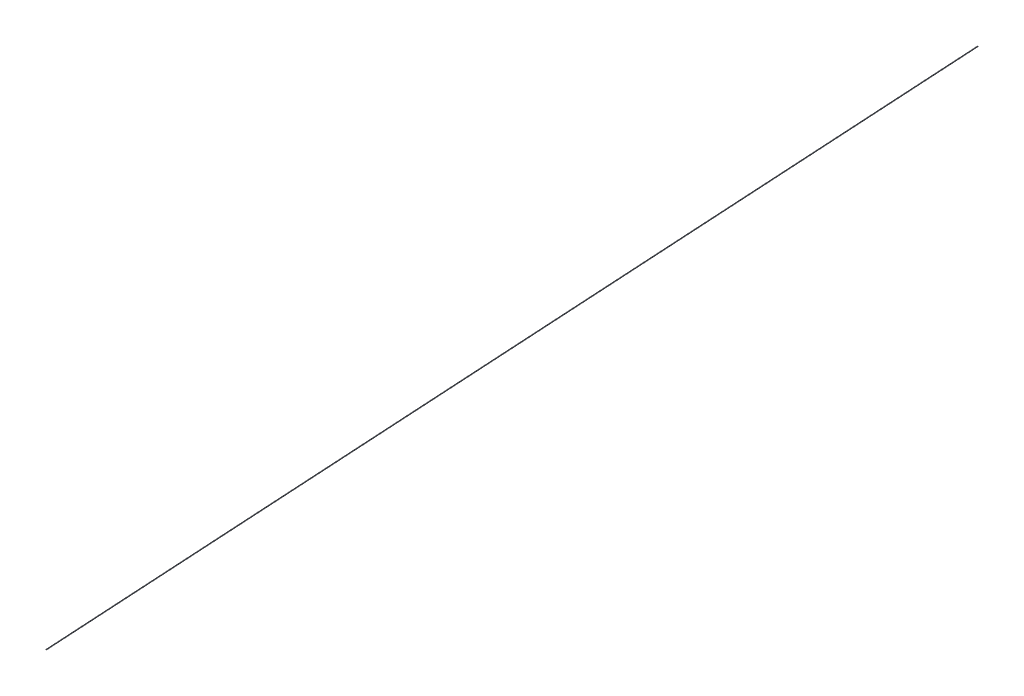
from build123d import *

# Parameters (mm, degrees)
SKETCH2_R = 3.8


with BuildPart() as part:
    # Sweep1: sweep along a path in Sketch1
    with BuildLine(Plane(origin=(0, 0, 0), x_dir=(0, 0, -1), z_dir=(1, 0, 0))) as sweep1_path:
        Line((14101.6, 857.6), (14091.6, 857.6))
        Line((14091.6, 857.6), (10, 0))
        Line((10, 0), (0, 0))
    # Sketch2 → Sweep1 (sweep)
    with BuildSketch(Plane.XY):
        Circle(SKETCH2_R)
    sweep(path=sweep1_path.line, transition=Transition.RIGHT)


solid = part.part
